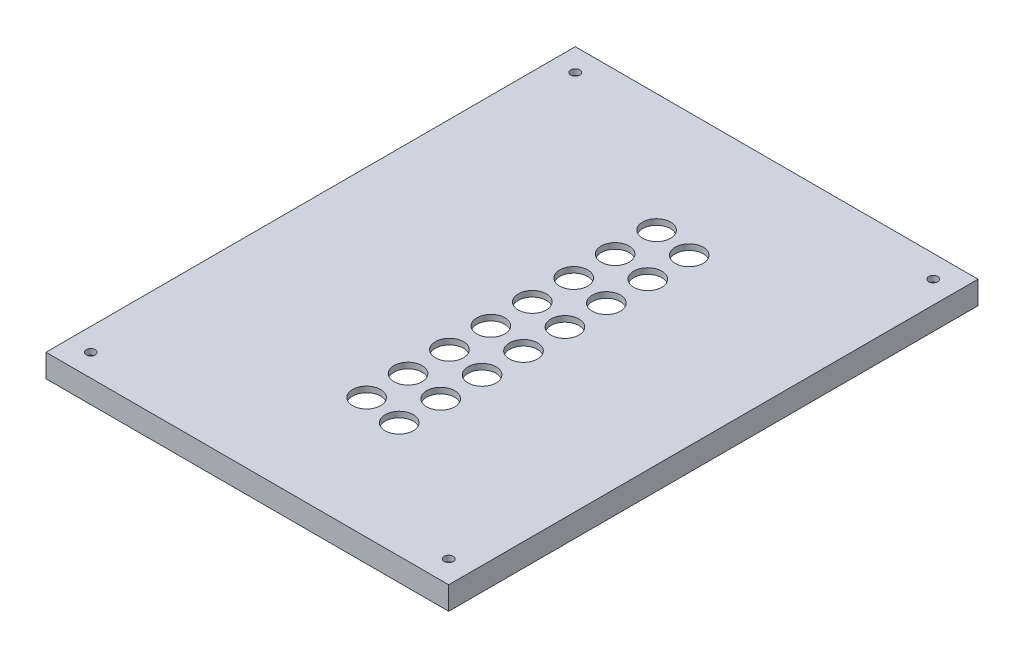
from build123d import *

# Parameters (mm, degrees)
SKETCH1_W                        = 209.55
SKETCH1_H                        = 279.399995444
SKETCH1_R                        = 2.5273
BOSS_EXTRUDE1_DEPTH              = 3.175
SKETCH2_W                        = 222.25
SKETCH2_H                        = 292.099995444
SKETCH2_W_2                      = 212.725
SKETCH2_H_2                      = 282.574995444
BOSS_EXTRUDE2_DEPTH              = 12.7
SKETCH2_2_W                      = 212.725
SKETCH2_2_H                      = 282.574995444
SKETCH2_2_W_2                    = 209.55
SKETCH2_2_H_2                    = 279.399995444
BOSS_EXTRUDE3_DEPTH              = 3.175
F_39_64_0_60938_DIAMETER_HOLE1_D = 15.478252


with BuildPart() as part:
    # Sketch1 → Boss-Extrude1 (new body)
    with BuildSketch(Plane(origin=(0, 0, 0), x_dir=(1, 0, 0), z_dir=(0, 1, 0))):
        with Locations((-68.646181354, 29.300553278)):
            Rectangle(SKETCH1_W, SKETCH1_H)
        with Locations((-167.421181354, -104.399444444)):
            Circle(SKETCH1_R, mode=Mode.SUBTRACT)
        with Locations((-167.421181354, 163.000555634)):
            Circle(SKETCH1_R, mode=Mode.SUBTRACT)
        with Locations((30.128818646, -104.399444444)):
            Circle(SKETCH1_R, mode=Mode.SUBTRACT)
        with Locations((30.128818646, 163.000555634)):
            Circle(SKETCH1_R, mode=Mode.SUBTRACT)
    extrude(amount=BOSS_EXTRUDE1_DEPTH)



with BuildPart() as body_2:
    # Sketch2 → Boss-Extrude2 (new body)
    with BuildSketch(Plane(origin=(0, 3.175, 0), x_dir=(1, 0, 0), z_dir=(0, 1, 0))):
        with Locations((-68.646181354, 29.300553278)):
            Rectangle(SKETCH2_W, SKETCH2_H)
        with Locations((-68.646181354, 29.300553278)):
            Rectangle(SKETCH2_W_2, SKETCH2_H_2, mode=Mode.SUBTRACT)
    extrude(amount=-BOSS_EXTRUDE2_DEPTH)


with BuildPart() as part_1:
    add(part.part)

    add(body_2.part)  # Boss-Extrude3 merges body 2
    # Sketch2_2 → Boss-Extrude3 (add)
    with BuildSketch(Plane(origin=(0, 3.175, 0), x_dir=(1, 0, 0), z_dir=(0, 1, 0))):
        with Locations((-68.646181354, 29.300553278)):
            Rectangle(SKETCH2_2_W, SKETCH2_2_H)
        with Locations((-68.646181354, 29.300553278)):
            Rectangle(SKETCH2_2_W_2, SKETCH2_2_H_2, mode=Mode.SUBTRACT)
    extrude(amount=-BOSS_EXTRUDE3_DEPTH)

    # 39_64 _0.60938_ Diameter Hole1 (through all)
    with Locations(Plane(origin=(0, 3.175, 0), x_dir=(1, 0, 0), z_dir=(0, 1, 0))):
        with Locations((-69.646181393, 110.086655576), (-48.646181397, 107.086655551), (-69.64618139, 87.226655576), (-48.646181393, 84.226655551), (-48.64618139, 61.366655551), (-69.646181387, 64.366655576), (-69.646181383, 41.506655576), (-48.646181387, 38.506655551), (-48.646181384, 15.646655551), (-69.64618138, 18.646655576), (-69.646181377, -4.213344424), (-48.646181381, -7.213344449), (-48.646181377, -30.073344449), (-69.646181374, -27.073344424), (-69.646181371, -49.933344424), (-48.646181374, -52.933344449)):
            Hole(F_39_64_0_60938_DIAMETER_HOLE1_D / 2)


solid = part_1.part
